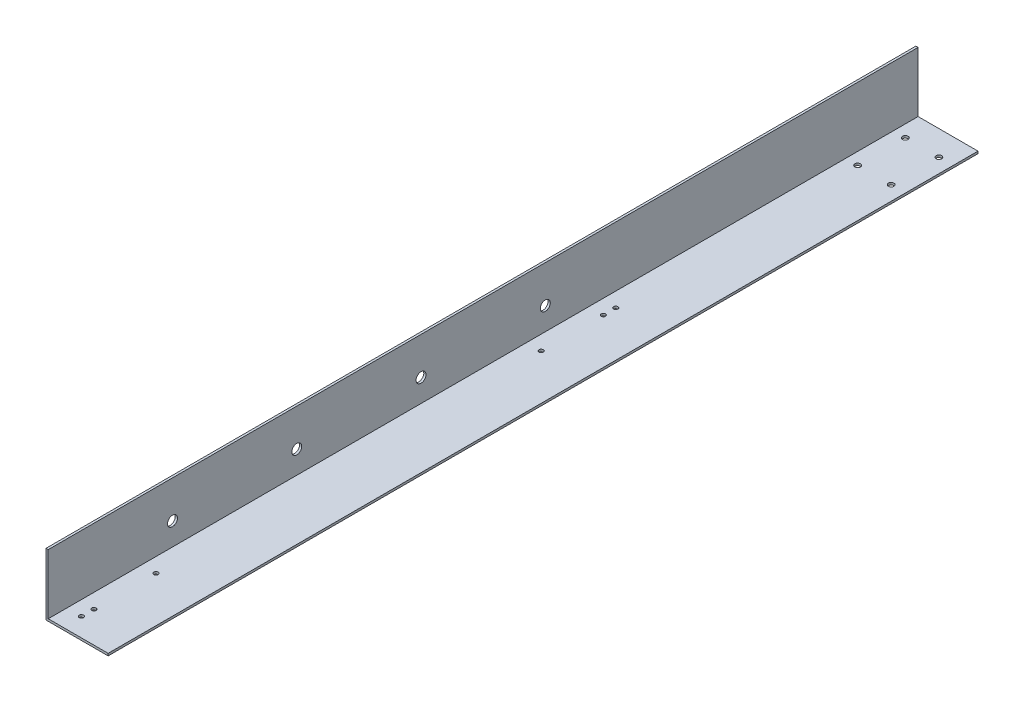
from build123d import *

# Parameters (mm, degrees)
EXTRUDE_1_DEPTH             = 700
SKETCH_2_R                  = 2.25
CUT_EXTRUDE_1_DEPTH         = 10
SKETCH_3_R                  = 4
CUT_EXTRUDE_2_DEPTH         = 51
HOLE_WIZARD_3_5_3_5_1_D     = 3.5
HOLE_WIZARD_3_5_3_5_1_DEPTH = 2
HOLE_WIZARD_3_5_3_5_1_TIP   = 1.051506083


with BuildPart() as part:
    # 草圖1 → 填料-伸長1 (new body)
    with BuildSketch(Plane.XY):
        Polygon((0, 50), (0, 0), (50, 0), (50, 1.8), (1.8, 1.8), (1.8, 50), align=None)
    extrude(amount=EXTRUDE_1_DEPTH)

    # 草圖2 → 除料-伸長1 (cut)
    with BuildSketch(Plane(origin=(0, 0, 0), x_dir=(-1, 0, 0), z_dir=(0, -1, 0))):
        with Locations((-38.5, -20)):
            Circle(SKETCH_2_R)
        with Locations((-38.5, -58.34)):
            Circle(SKETCH_2_R)
        with Locations((-11.5, -20)):
            Circle(SKETCH_2_R)
        with Locations((-11.5, -58.34)):
            Circle(SKETCH_2_R)
    extrude(amount=-CUT_EXTRUDE_1_DEPTH, mode=Mode.SUBTRACT)

    # 草圖3 → 除料-伸長2 (cut, through all)
    with BuildSketch(Plane.ZY):
        with Locations((600, 20)):
            Circle(SKETCH_3_R)
        with Locations((500, 20)):
            Circle(SKETCH_3_R)
        with Locations((400, 20)):
            Circle(SKETCH_3_R)
        with Locations((300, 20)):
            Circle(SKETCH_3_R)
    extrude(amount=-CUT_EXTRUDE_2_DEPTH, mode=Mode.SUBTRACT)

    # Ø3.5 (3.5) 直徑孔1
    with Locations(Plane(origin=(0, 0, 0), x_dir=(-1, 0, 0), z_dir=(0, -1, 0))):
        with Locations((-13.5, -685), (-13.5, -675), (-13.5, -625), (-13.5, -255), (-13.5, -265), (-13.5, -315)):
            Hole(HOLE_WIZARD_3_5_3_5_1_D / 2, depth=HOLE_WIZARD_3_5_3_5_1_DEPTH)
            with Locations((0, 0, -(HOLE_WIZARD_3_5_3_5_1_DEPTH + HOLE_WIZARD_3_5_3_5_1_TIP / 2))):  # 118° drill point
                Cone(0, HOLE_WIZARD_3_5_3_5_1_D / 2, HOLE_WIZARD_3_5_3_5_1_TIP, mode=Mode.SUBTRACT)


solid = part.part
